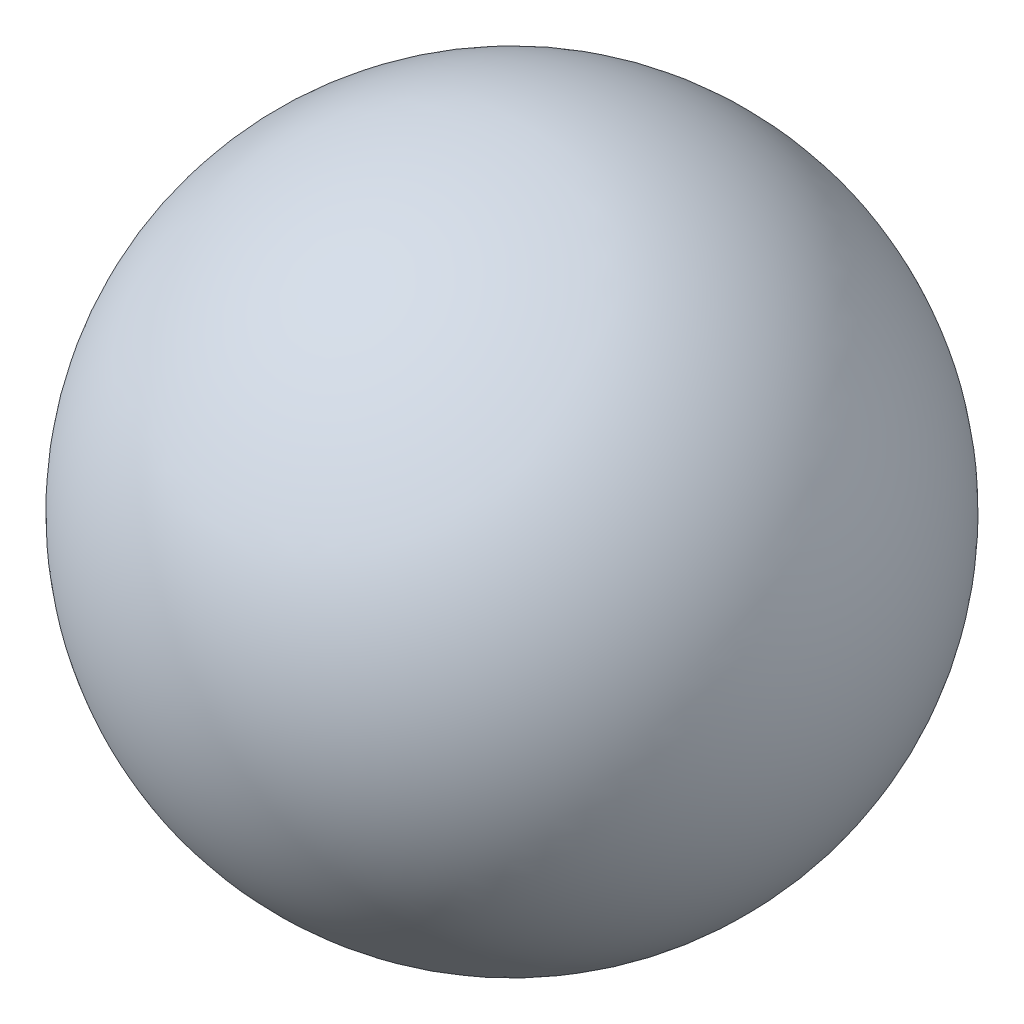
from build123d import *


with BuildPart() as part:
    # Esboço1 → Revolução1 (revolve)
    with BuildSketch(Plane(origin=(0, 0, 0), x_dir=(1, 0, 0), z_dir=(0, 1, 0))):
        with BuildLine():
            Line((0, 2.25), (0, -2.25))
            ThreePointArc((0, -2.25), (2.25, 0), (0, 2.25))
        make_face()
    revolve(axis=Axis((0, 0, -3.602834961), (0, 0, 1)))


solid = part.part
